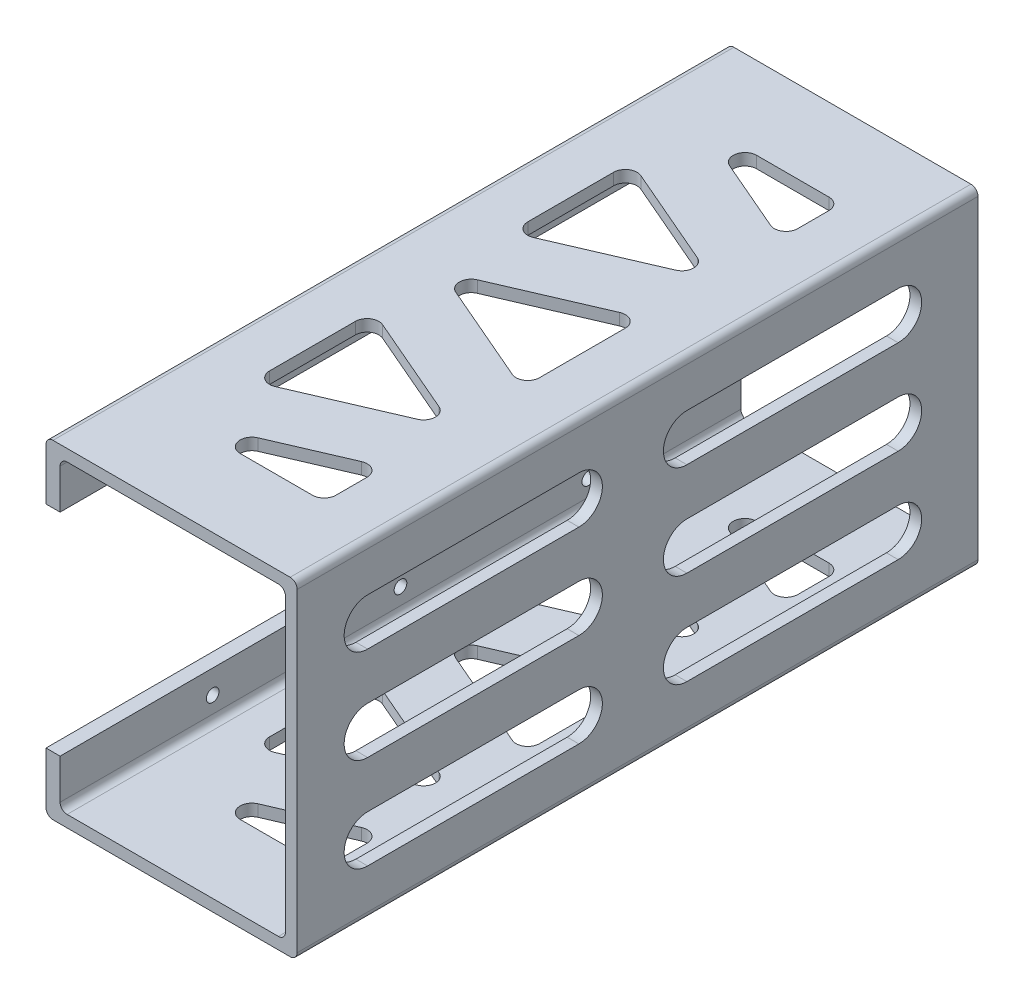
from build123d import *

# Parameters (mm, degrees)
EXTRUDE_1_DEPTH     = 145
SKETCH_2_R          = 1.35
CUT_EXTRUDE_1_DEPTH = 3
CUT_EXTRUDE_2_DEPTH = 2.5
CUT_EXTRUDE_3_DEPTH = 70
FILLET_1_R          = 2.5
FILLET_2_R          = 1.5


with BuildPart() as part:
    # 草图1 → 凸台-拉伸1 (new body)
    with BuildSketch(Plane.XY):
        Polygon((-13, -35.966337082), (-13, -23.466337082), (40.5, -23.466337082), (40.5, -93.466337082), (-13, -93.466337082), (-13, -80.966337082), (-10, -80.966337082), (-10, -90.966337082), (38, -90.966337082), (38, -25.966337082), (-10, -25.966337082), (-10, -35.966337082), align=None)
    extrude(amount=-EXTRUDE_1_DEPTH)

    # 草图2 → 切除-拉伸1 (cut)
    with BuildSketch(Plane.ZY.offset(13)):
        with Locations((-112.5, -30.966337082)):
            Circle(SKETCH_2_R)
        with Locations((-72.5, -30.966337082)):
            Circle(SKETCH_2_R)
        with Locations((-32.5, -30.966337082)):
            Circle(SKETCH_2_R)
        with Locations((-32.5, -85.966337082)):
            Circle(SKETCH_2_R)
        with Locations((-72.5, -85.966337082)):
            Circle(SKETCH_2_R)
        with Locations((-112.5, -85.966337082)):
            Circle(SKETCH_2_R)
    extrude(amount=-CUT_EXTRUDE_1_DEPTH, mode=Mode.SUBTRACT)

    # 草图3 → 切除-拉伸2 (cut)
    with BuildSketch(Plane.ZY.offset(-38)):
        with BuildLine():
            Line((-128, -33.466337082), (-83, -33.466337082))
            ThreePointArc((-83, -33.466337082), (-78, -38.466337082), (-83, -43.466337082))
            Line((-83, -43.466337082), (-128, -43.466337082))
            ThreePointArc((-128, -43.466337082), (-133, -38.466337082), (-128, -33.466337082))
        make_face()
        with BuildLine():
            Line((-128, -53.466337082), (-83, -53.466337082))
            ThreePointArc((-83, -53.466337082), (-78, -58.466337082), (-83, -63.466337082))
            Line((-83, -63.466337082), (-128, -63.466337082))
            ThreePointArc((-128, -63.466337082), (-133, -58.466337082), (-128, -53.466337082))
        make_face()
        with BuildLine():
            Line((-128, -73.466337082), (-83, -73.466337082))
            ThreePointArc((-83, -73.466337082), (-78, -78.466337082), (-83, -83.466337082))
            Line((-83, -83.466337082), (-128, -83.466337082))
            ThreePointArc((-128, -83.466337082), (-133, -78.466337082), (-128, -73.466337082))
        make_face()
        with BuildLine():
            Line((-60, -33.466337082), (-15, -33.466337082))
            ThreePointArc((-15, -33.466337082), (-10, -38.466337082), (-15, -43.466337082))
            Line((-15, -43.466337082), (-60, -43.466337082))
            ThreePointArc((-60, -43.466337082), (-65, -38.466337082), (-60, -33.466337082))
        make_face()
        with BuildLine():
            Line((-60, -53.466337082), (-15, -53.466337082))
            ThreePointArc((-15, -53.466337082), (-10, -58.466337082), (-15, -63.466337082))
            Line((-15, -63.466337082), (-60, -63.466337082))
            ThreePointArc((-60, -63.466337082), (-65, -58.466337082), (-60, -53.466337082))
        make_face()
        with BuildLine():
            Line((-60, -73.466337082), (-15, -73.466337082))
            ThreePointArc((-15, -73.466337082), (-10, -78.466337082), (-15, -83.466337082))
            Line((-15, -83.466337082), (-60, -83.466337082))
            ThreePointArc((-60, -83.466337082), (-65, -78.466337082), (-60, -73.466337082))
        make_face()
    extrude(amount=-CUT_EXTRUDE_2_DEPTH, mode=Mode.SUBTRACT)

    # 草图4 → 切除-拉伸3 (cut)
    with BuildSketch(Plane(origin=(0, -23.466337082, 0), x_dir=(1, 0, 0), z_dir=(0, 1, 0))):
        Polygon((28.75, 85.438393953), (-1.25, 72.5), (28.75, 59.561606047), align=None)
        Polygon((-1.25, 127.5), (28.75, 114.561606047), (28.75, 127.5), align=None)
        Polygon((-1.25, 112.938393953), (28.75, 100), (-1.25, 87.061606047), align=None)
        Polygon((-1.25, 57.938393953), (28.75, 45), (-1.25, 32.061606047), align=None)
        Polygon((-1.25, 17.5), (28.75, 30.438393953), (28.75, 17.5), align=None)
    extrude(amount=-CUT_EXTRUDE_3_DEPTH, mode=Mode.SUBTRACT)

    # 圆角1
    fillet_1_edges = [part.edges().sort_by_distance(p)[0] for p in [
        (-1.25, -92.216337082, -127.5),
        (28.75, -92.216337082, -127.5),
        (28.75, -92.216337082, -114.561606047),
        (-1.25, -24.716337082, -127.5),
        (28.75, -24.716337082, -127.5),
        (28.75, -24.716337082, -114.561606047),
        (-1.25, -92.216337082, -32.061606047),
        (-1.25, -92.216337082, -57.938393953),
        (28.75, -92.216337082, -45),
        (-1.25, -24.716337082, -32.061606047),
        (-1.25, -24.716337082, -57.938393953),
        (28.75, -24.716337082, -45),
        (-1.25, -92.216337082, -87.061606047),
        (-1.25, -92.216337082, -112.938393953),
        (28.75, -92.216337082, -100),
        (-1.25, -24.716337082, -87.061606047),
        (-1.25, -24.716337082, -112.938393953),
        (28.75, -24.716337082, -100),
        (28.75, -92.216337082, -85.438393953),
        (28.75, -92.216337082, -59.561606047),
        (-1.25, -92.216337082, -72.5),
        (28.75, -24.716337082, -85.438393953),
        (28.75, -24.716337082, -59.561606047),
        (-1.25, -24.716337082, -72.5),
        (28.75, -92.216337082, -17.5),
        (-1.25, -92.216337082, -17.5),
        (28.75, -92.216337082, -30.438393953),
        (28.75, -24.716337082, -17.5),
        (-1.25, -24.716337082, -17.5),
        (28.75, -24.716337082, -30.438393953),
    ]]
    fillet(fillet_1_edges, radius=FILLET_1_R)

    # 圆角2
    fillet_2_edges = [part.edges().sort_by_distance(p)[0] for p in [
        (-13, -23.466337082, -72.5),
        (40.5, -23.466337082, -72.5),
        (40.5, -93.466337082, -72.5),
        (-13, -93.466337082, -72.5),
        (-10, -90.966337082, -72.5),
        (38, -90.966337082, -72.5),
        (38, -25.966337082, -72.5),
        (-10, -25.966337082, -72.5),
    ]]
    fillet(fillet_2_edges, radius=FILLET_2_R)


solid = part.part
